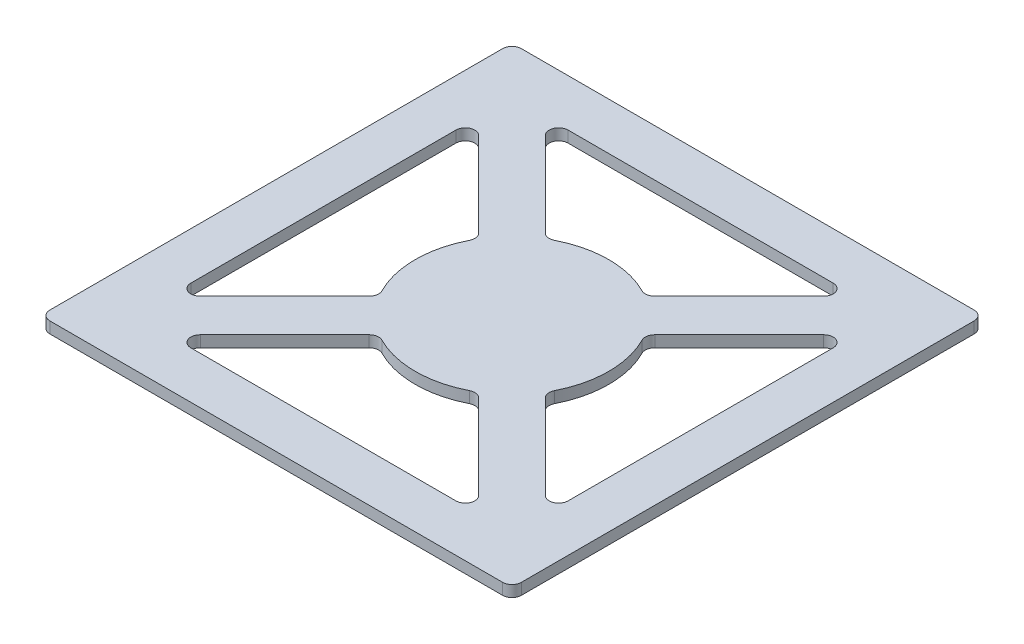
from build123d import *

# Parameters (mm, degrees)
SKETCH1_W           = 500
SKETCH1_H           = 500
BOSS_EXTRUDE1_DEPTH = 12
CUT_EXTRUDE1_DEPTH  = 12
FILLET1_R           = 10


with BuildPart() as part:
    # Sketch1 → Boss-Extrude1 (new body)
    with BuildSketch(Plane(origin=(0, 0, 0), x_dir=(1, 0, 0), z_dir=(0, 1, 0))):
        Rectangle(SKETCH1_W, SKETCH1_H)
    extrude(amount=BOSS_EXTRUDE1_DEPTH)

    # Sketch2 → Cut-Extrude1 (cut)
    with BuildSketch(Plane(origin=(0, 12, 0), x_dir=(1, 0, 0), z_dir=(0, 1, 0))):
        with BuildLine():
            Line((-200, 164.644660941), (-88.091394352, 52.736055293))
            ThreePointArc((-88.091394352, 52.736055293), (-102.670274602, 0), (-88.091394352, -52.736055293))
            Line((-88.091394352, -52.736055293), (-200, -164.644660941))
            Line((-200, -164.644660941), (-200, 164.644660941))
        make_face()
        with BuildLine():
            Line((164.644660941, 200), (52.736055293, 88.091394352))
            ThreePointArc((52.736055293, 88.091394352), (0, 102.670274602), (-52.736055293, 88.091394352))
            Line((-52.736055293, 88.091394352), (-164.644660941, 200))
            Line((-164.644660941, 200), (164.644660941, 200))
        make_face()
        with BuildLine():
            Line((200, 164.644660941), (88.091394352, 52.736055293))
            ThreePointArc((88.091394352, 52.736055293), (102.670274602, 0), (88.091394352, -52.736055293))
            Line((88.091394352, -52.736055293), (200, -164.644660941))
            Line((200, -164.644660941), (200, 164.644660941))
        make_face()
        with BuildLine():
            Line((-164.644660941, -200), (164.644660941, -200))
            Line((164.644660941, -200), (52.736055293, -88.091394352))
            ThreePointArc((52.736055293, -88.091394352), (0, -102.670274602), (-52.736055293, -88.091394352))
            Line((-52.736055293, -88.091394352), (-164.644660941, -200))
        make_face()
    extrude(amount=-CUT_EXTRUDE1_DEPTH, mode=Mode.SUBTRACT)

    # Fillet1
    fillet1_edges = [part.edges().sort_by_distance(p)[0] for p in [
        (-200, 6, 164.644660941),
        (-200, 6, -164.644660941),
        (-88.091394352, 6, -52.736055293),
        (-88.091394352, 6, 52.736055293),
        (-164.644660941, 6, -200),
        (164.644660941, 6, -200),
        (52.736055293, 6, -88.091394352),
        (-52.736055293, 6, -88.091394352),
        (52.736055293, 6, 88.091394352),
        (164.644660941, 6, 200),
        (-164.644660941, 6, 200),
        (-52.736055293, 6, 88.091394352),
        (88.091394352, 6, 52.736055293),
        (88.091394352, 6, -52.736055293),
        (200, 6, -164.644660941),
        (200, 6, 164.644660941),
        (-250, 6, -250),
        (250, 6, -250),
        (250, 6, 250),
        (-250, 6, 250),
    ]]
    fillet(fillet1_edges, radius=FILLET1_R)


solid = part.part
